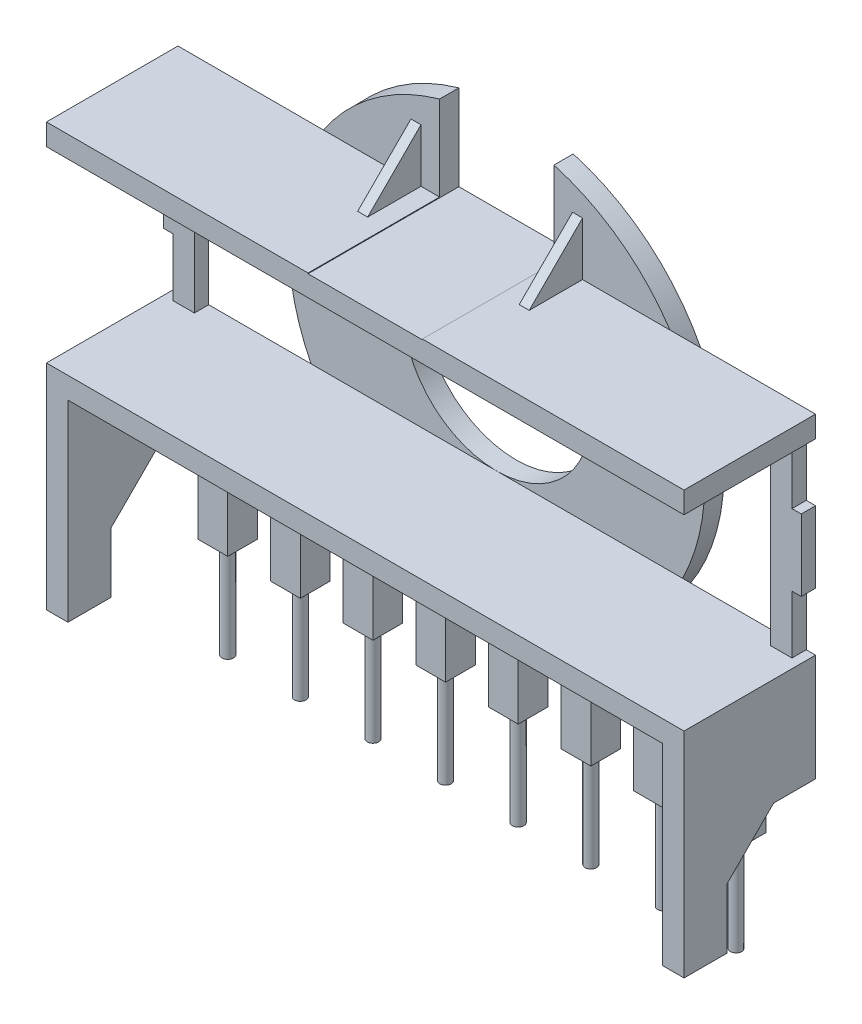
from build123d import *

# Parameters (mm, degrees)
SKETCH1_R           = 6.55
BOSS_EXTRUDE1_DEPTH = 1.35
SKETCH2_W           = 0.7
SKETCH2_H           = 3.730882663
SKETCH2_W_2         = 1.5
SKETCH2_H_2         = 13.460629035
BOSS_EXTRUDE2_DEPTH = 9.2
SKETCH3_W           = 1.5
SKETCH3_H           = 13.1
SKETCH3_W_2         = 0.65
SKETCH3_H_2         = 5
BOSS_EXTRUDE3_DEPTH = 1
CUT_EXTRUDE1_DEPTH  = 29.3
CUT_EXTRUDE2_DEPTH  = 45.6
SKETCH7_W           = 41.6
SKETCH7_H           = 7
BOSS_EXTRUDE4_DEPTH = 0.5
SKETCH8_R           = 0.4
PINS_DEPTH          = 11
PINS_2_DEPTH        = 11
PINS_3_DEPTH        = 11
PINS_4_DEPTH        = 11
PINS_5_DEPTH        = 11
PINS_6_DEPTH        = 11
PINS_7_DEPTH        = 11
PINS_8_DEPTH        = 11
SKETCH9_W           = 2.08
SKETCH9_H           = 2.08
BOSS_EXTRUDE6_DEPTH = 11


with BuildPart() as part:
    # Sketch1 → Boss-Extrude1 (new body)
    with BuildSketch(Plane.XY):
        with BuildLine():
            Line((0, 8), (-4, 8))
            Line((-4, 8), (-4, 13.989370965))
            ThreePointArc((-4, 13.989370965), (-8.760779075, -11.616851983), (14.55, 0))
            ThreePointArc((14.55, 0), (11.616851983, 8.760779075), (4, 13.989370965))
            Line((4, 13.989370965), (4, 8))
            Line((4, 8), (0, 8))
        make_face()
        Circle(SKETCH1_R, mode=Mode.SUBTRACT)
    extrude(amount=BOSS_EXTRUDE1_DEPTH)

    # Sketch2 → Boss-Extrude2 (add)
    with BuildSketch(Plane.XY.offset(1.35)):
        with BuildLine():
            ThreePointArc((12.120231021, 8.05), (12.578647446, 7.313010901), (12.992305415, 6.55))
            Line((12.992305415, 6.55), (22.3, 6.55))
            Line((22.3, 6.55), (22.3, 8.05))
            Line((22.3, 8.05), (12.120231021, 8.05))
        make_face()
        with Locations((5.65, 9.915441332)):
            Rectangle(SKETCH2_W, SKETCH2_H)
        with BuildLine():
            Line((-5.3, 8.05), (-6, 8.05))
            Line((-6, 8.05), (-12.120231021, 8.05))
            ThreePointArc((-12.120231021, 8.05), (-12.578647446, 7.313010901), (-12.992305415, 6.55))
            Line((-12.992305415, 6.55), (12.992305415, 6.55))
            ThreePointArc((12.992305415, 6.55), (12.578647446, 7.313010901), (12.120231021, 8.05))
            Line((12.120231021, 8.05), (6, 8.05))
            Line((6, 8.05), (5.3, 8.05))
            Line((5.3, 8.05), (4, 8.05))
            Line((4, 8.05), (4, 8))
            Line((4, 8), (-4, 8))
            Line((-4, 8), (-4, 8.05))
            Line((-4, 8.05), (-5.3, 8.05))
        make_face()
        with BuildLine():
            ThreePointArc((-12.992305415, 6.55), (-12.578647446, 7.313010901), (-12.120231021, 8.05))
            Line((-12.120231021, 8.05), (-22.3, 8.05))
            Line((-22.3, 8.05), (-22.3, 6.55))
            Line((-22.3, 6.55), (-12.992305415, 6.55))
        make_face()
        with Locations((-21.55, -14.780314518)):
            Rectangle(SKETCH2_W_2, SKETCH2_H_2)
        with BuildLine():
            ThreePointArc((-12.120231021, -8.05), (-12.578647446, -7.313010901), (-12.992305415, -6.55))
            Line((-12.992305415, -6.55), (-22.3, -6.55))
            Line((-22.3, -6.55), (-22.3, -8.05))
            Line((-22.3, -8.05), (-20.8, -8.05))
            Line((-20.8, -8.05), (-12.120231021, -8.05))
        make_face()
        with BuildLine():
            Line((12.992305415, -6.55), (-12.992305415, -6.55))
            ThreePointArc((-12.992305415, -6.55), (-12.578647446, -7.313010901), (-12.120231021, -8.05))
            Line((-12.120231021, -8.05), (12.120231021, -8.05))
            ThreePointArc((12.120231021, -8.05), (12.578647446, -7.313010901), (12.992305415, -6.55))
        make_face()
        with BuildLine():
            Line((22.3, -6.55), (12.992305415, -6.55))
            ThreePointArc((12.992305415, -6.55), (12.578647446, -7.313010901), (12.120231021, -8.05))
            Line((12.120231021, -8.05), (20.8, -8.05))
            Line((20.8, -8.05), (22.3, -8.05))
            Line((22.3, -8.05), (22.3, -6.55))
        make_face()
        with Locations((21.55, -14.780314518)):
            Rectangle(SKETCH2_W_2, SKETCH2_H_2)
        with Locations((-5.65, 9.915441332)):
            Rectangle(SKETCH2_W, SKETCH2_H)
    extrude(amount=BOSS_EXTRUDE2_DEPTH)

    # Sketch3 → Boss-Extrude3 (add)
    with BuildSketch(Plane.XY.offset(1.35)):
        with Locations((-20.9, 0)):
            Rectangle(SKETCH3_W, SKETCH3_H)
        with Locations((-21.975, 0)):
            Rectangle(SKETCH3_W_2, SKETCH3_H_2)
        with Locations((21.975, 0)):
            Rectangle(SKETCH3_W_2, SKETCH3_H_2)
        with Locations((20.9, 0)):
            Rectangle(SKETCH3_W, SKETCH3_H)
    extrude(amount=BOSS_EXTRUDE3_DEPTH)

    # Sketch5 → Cut-Extrude1 (cut, through all)
    with BuildSketch(Plane(origin=(6, 0, 0), x_dir=(0, 0, -1), z_dir=(1, 0, 0))):
        Polygon((-10.55, 8.05), (-5.080882663, 8.05), (-1.35, 11.780882663), (-10.55, 11.780882663), align=None)
    extrude(amount=-CUT_EXTRUDE1_DEPTH, mode=Mode.SUBTRACT)

    # Sketch6 → Cut-Extrude2 (cut, through all)
    with BuildSketch(Plane(origin=(22.3, 0, 0), x_dir=(0, 0, -1), z_dir=(1, 0, 0))):
        Polygon((-7.55, -21.510629035), (-7.55, -17.317508604), (-4.282491396, -14.05), (-1.35, -14.05), (-1.35, -21.510629035), align=None)
    extrude(amount=-CUT_EXTRUDE2_DEPTH, mode=Mode.SUBTRACT)

    # Sketch7 → Boss-Extrude4 (add)
    with BuildSketch(Plane.XY.offset(1.35)):
        with Locations((0, -11.55)):
            Rectangle(SKETCH7_W, SKETCH7_H)
    extrude(amount=BOSS_EXTRUDE4_DEPTH)



with BuildPart() as body_2:
    # Sketch8 → Pins (new body)
    with BuildSketch(Plane.XZ.offset(15.05)):
        with Locations((-17.78, 2.39)):
            Circle(SKETCH8_R)
    extrude(amount=PINS_DEPTH)


with BuildPart() as body_3:
    # Sketch8 → Pins 2 (new body)
    with BuildSketch(Plane.XZ.offset(15.05)):
        with Locations((-12.7, 2.39)):
            Circle(SKETCH8_R)
    extrude(amount=PINS_2_DEPTH)


with BuildPart() as body_4:
    # Sketch8 → Pins 3 (new body)
    with BuildSketch(Plane.XZ.offset(15.05)):
        with Locations((-7.62, 2.39)):
            Circle(SKETCH8_R)
    extrude(amount=PINS_3_DEPTH)


with BuildPart() as body_5:
    # Sketch8 → Pins 4 (new body)
    with BuildSketch(Plane.XZ.offset(15.05)):
        with Locations((-2.54, 2.39)):
            Circle(SKETCH8_R)
    extrude(amount=PINS_4_DEPTH)


with BuildPart() as body_6:
    # Sketch8 → Pins 5 (new body)
    with BuildSketch(Plane.XZ.offset(15.05)):
        with Locations((2.54, 2.39)):
            Circle(SKETCH8_R)
    extrude(amount=PINS_5_DEPTH)


with BuildPart() as body_7:
    # Sketch8 → Pins 6 (new body)
    with BuildSketch(Plane.XZ.offset(15.05)):
        with Locations((7.62, 2.39)):
            Circle(SKETCH8_R)
    extrude(amount=PINS_6_DEPTH)


with BuildPart() as body_8:
    # Sketch8 → Pins 7 (new body)
    with BuildSketch(Plane.XZ.offset(15.05)):
        with Locations((12.7, 2.39)):
            Circle(SKETCH8_R)
    extrude(amount=PINS_7_DEPTH)


with BuildPart() as body_9:
    # Sketch8 → Pins 8 (new body)
    with BuildSketch(Plane.XZ.offset(15.05)):
        with Locations((17.78, 2.39)):
            Circle(SKETCH8_R)
    extrude(amount=PINS_8_DEPTH)


with BuildPart() as part_1:
    add(part.part)

    add(body_2.part)  # Boss-Extrude6 merges body 2

    add(body_3.part)  # Boss-Extrude6 merges body 3

    add(body_4.part)  # Boss-Extrude6 merges body 4

    add(body_5.part)  # Boss-Extrude6 merges body 5

    add(body_6.part)  # Boss-Extrude6 merges body 6

    add(body_7.part)  # Boss-Extrude6 merges body 7

    add(body_8.part)  # Boss-Extrude6 merges body 8

    add(body_9.part)  # Boss-Extrude6 merges body 9
    # Sketch9 → Boss-Extrude6 (add)
    with BuildSketch(Plane.XZ.offset(8.05)):
        with Locations((-12.7, 2.39)):
            Rectangle(SKETCH9_W, SKETCH9_H)
        with Locations((-17.78, 2.39)):
            Rectangle(SKETCH9_W, SKETCH9_H)
        with Locations((-7.62, 2.39)):
            Rectangle(SKETCH9_W, SKETCH9_H)
        with Locations((-2.54, 2.39)):
            Rectangle(SKETCH9_W, SKETCH9_H)
        with Locations((2.54, 2.39)):
            Rectangle(SKETCH9_W, SKETCH9_H)
        with Locations((7.62, 2.39)):
            Rectangle(SKETCH9_W, SKETCH9_H)
        with Locations((12.7, 2.39)):
            Rectangle(SKETCH9_W, SKETCH9_H)
        with Locations((17.78, 2.39)):
            Rectangle(SKETCH9_W, SKETCH9_H)
    extrude(amount=BOSS_EXTRUDE6_DEPTH)


solid = part_1.part
